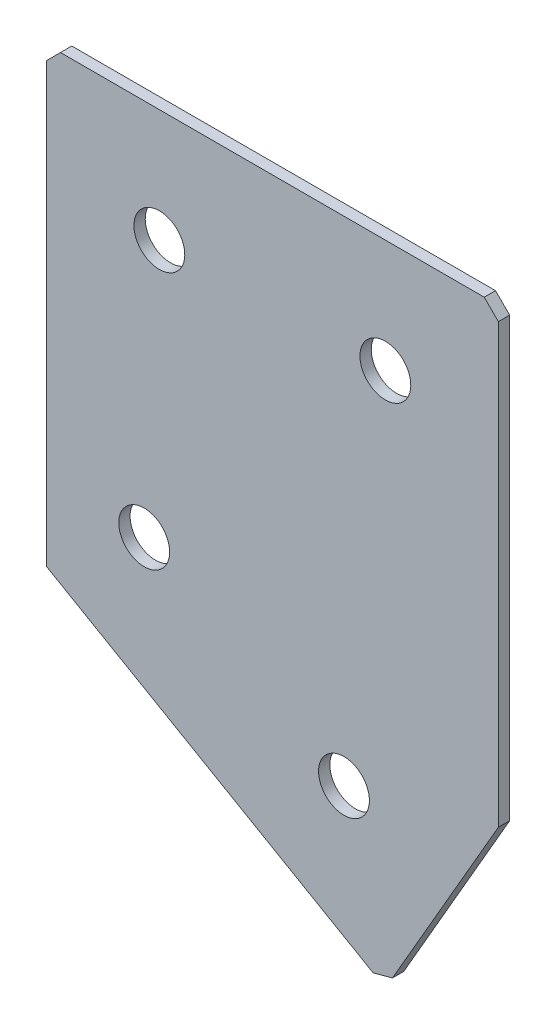
from build123d import *

# Parameters (mm, degrees)
EXTRUDE_1_DEPTH   = 2
HOLE_WIZARD_M81_D = 9
CHAMFER_1_SIZE    = 2.5


with BuildPart() as part:
    # Эскиз3 → Бобышка-Вытянуть1 (new body)
    with BuildSketch(Plane(origin=(0, 0, 0), x_dir=(1, 0, 0), z_dir=(0, 0, -1))):
        Polygon((0, 0), (80, 0), (80, 80), (60, 114.641016151), (0, 80), align=None)
    extrude(amount=EXTRUDE_1_DEPTH)

    # Отверстие с зазором M81 (through all)
    with Locations(Plane(origin=(0, 0, -2), x_dir=(1, 0, 0), z_dir=(0, 0, -1))):
        with Locations((20, 20), (60, 20), (17.320508076, 66.905989232), (52.679491924, 87.320508076)):
            Hole(HOLE_WIZARD_M81_D / 2)

    # Фаска1
    chamfer_1_edges = [part.edges().sort_by_distance(p)[0] for p in [
        (60, -114.641016151, -1),
        (80, 0, -1),
        (0, 0, -1),
    ]]
    chamfer(chamfer_1_edges, length=CHAMFER_1_SIZE)


solid = part.part
